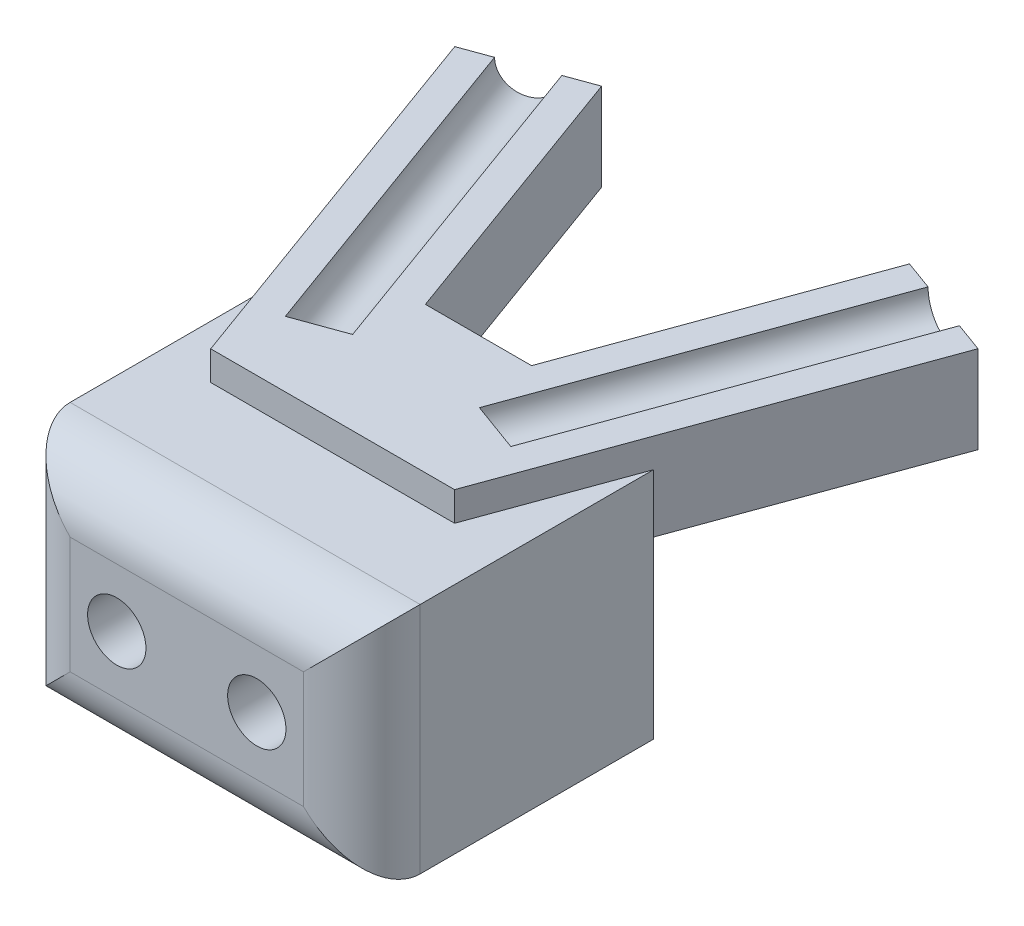
from build123d import *

# Parameters (mm, degrees)
SKETCH_1_W          = 6
SKETCH_1_H          = 4
EXTRUDE_1_DEPTH     = 5
SKETCH_2_R          = 0.5
CUT_EXTRUDE_1_DEPTH = 5
EXTRUDE_2_DEPTH     = 0.5
EXTRUDE_3_DEPTH     = 1
SKETCH_5_R          = 0.45
CUT_EXTRUDE_2_DEPTH = 6
FILLET_1_R          = 1


with BuildPart() as part:
    # 草图1 → 凸台-拉伸1 (new body)
    with BuildSketch(Plane.XY):
        Rectangle(SKETCH_1_W, SKETCH_1_H)
    extrude(amount=EXTRUDE_1_DEPTH)

    # 草图2 → 切除-拉伸1 (cut)
    with BuildSketch(Plane(origin=(0, 0, 0), x_dir=(-1, 0, 0), z_dir=(0, 0, -1))):
        with Locations((-1.2, 0)):
            Circle(SKETCH_2_R)
        with Locations((1.2, 0)):
            Circle(SKETCH_2_R)
    extrude(amount=-CUT_EXTRUDE_1_DEPTH, mode=Mode.SUBTRACT)

    # 草图3 → 凸台-拉伸2 (add)
    with BuildSketch(Plane(origin=(0, 2, 0), x_dir=(1, 0, 0), z_dir=(0, 1, 0))):
        Polygon((-2.090074414, -2.5), (2.090074414, -2.5), (4.484215418, 4.077848346), (2.638633265, 4.749585314), (0.909925586, 0), (-0.909925586, 0), (-2.638633265, 4.749585314), (-4.484215418, 4.077848346), align=None)
    extrude(amount=EXTRUDE_2_DEPTH)

    # 草图3<7> → 凸台-拉伸3 (add)
    with BuildSketch(Plane(origin=(0, 2, 0), x_dir=(1, 0, 0), z_dir=(0, 1, 0))):
        Polygon((-2.090074414, -2.5), (0, -2.5), (-2.638633265, 4.749585314), (-4.484215418, 4.077848346), align=None)
        Polygon((0, -2.5), (2.090074414, -2.5), (4.484215418, 4.077848346), (2.638633265, 4.749585314), align=None)
    extrude(amount=-EXTRUDE_3_DEPTH)

    # 草图5 → 切除-拉伸2 (cut)
    with BuildSketch(Plane(origin=(-1.835148753, 0, -5.04202976), x_dir=(-0.9396926207859081, 0, 0.34202014332566977), z_dir=(-0.3420201433256697, 0, -0.939692620785908))):
        with Locations((1.83706411, 2.5)):
            Circle(SKETCH_5_R)
    cut_extrude_2 = extrude(amount=-CUT_EXTRUDE_2_DEPTH, mode=Mode.SUBTRACT)

    # 镜向1: 切除-拉伸2 across plane
    add(cut_extrude_2.mirror(Plane(origin=(0, 0, 0), x_dir=(0, 0, 1), z_dir=(1, 0, 0))), mode=Mode.SUBTRACT)

    # 圆角1
    fillet_1_edges = [part.edges().sort_by_distance(p)[0] for p in [
        (-3, 0, 5),
        (3, 0, 5),
        (0, -2, 5),
        (0, 2, 5),
    ]]
    fillet(fillet_1_edges, radius=FILLET_1_R)


solid = part.part
